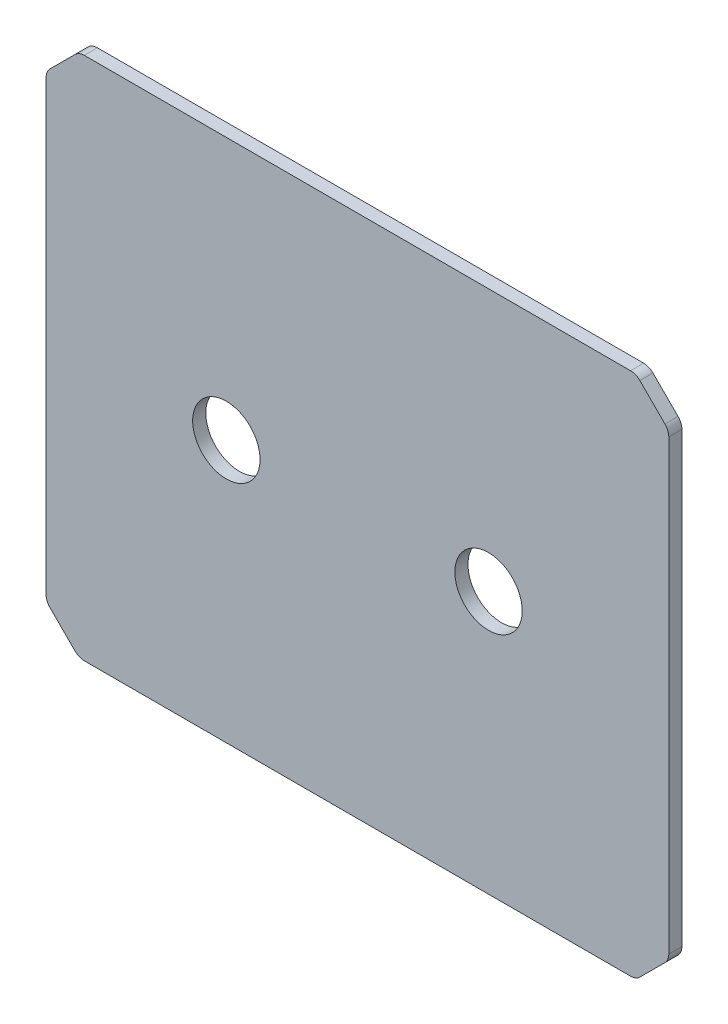
from build123d import *

# Parameters (mm, degrees)
SKETCH1_W           = 60.325
SKETCH1_H           = 50.8
BOSS_EXTRUDE1_DEPTH = 1.27
SKETCH3_R           = 3.2639
CUT_EXTRUDE1_DEPTH  = 2.27
CHAMFER1_SIZE       = 3.175
FILLET1_R           = 1.27


with BuildPart() as part:
    # Sketch1 → Boss-Extrude1 (new body)
    with BuildSketch(Plane.XY):
        with Locations((30.1625, 25.4)):
            Rectangle(SKETCH1_W, SKETCH1_H)
    extrude(amount=BOSS_EXTRUDE1_DEPTH)

    # Sketch3 → Cut-Extrude1 (cut, through all)
    with BuildSketch(Plane.XY.offset(1.27)):
        with Locations((42.8625, 25.4)):
            Circle(SKETCH3_R)
        with Locations((17.4625, 25.4)):
            Circle(SKETCH3_R)
    extrude(amount=-CUT_EXTRUDE1_DEPTH, mode=Mode.SUBTRACT)

    # Chamfer1
    chamfer1_edges = [part.edges().sort_by_distance(p)[0] for p in [
        (0, 0, 0.635),
        (0, 50.8, 0.635),
        (60.325, 50.8, 0.635),
        (60.325, 0, 0.635),
    ]]
    chamfer(chamfer1_edges, length=CHAMFER1_SIZE)

    # Fillet1
    fillet1_edges = [part.edges().sort_by_distance(p)[0] for p in [
        (57.15, 0, 0.635),
        (3.175, 0, 0.635),
        (0, 47.625, 0.635),
        (0, 3.175, 0.635),
        (57.15, 50.8, 0.635),
        (3.175, 50.8, 0.635),
        (60.325, 3.175, 0.635),
        (60.325, 47.625, 0.635),
    ]]
    fillet(fillet1_edges, radius=FILLET1_R)


solid = part.part
